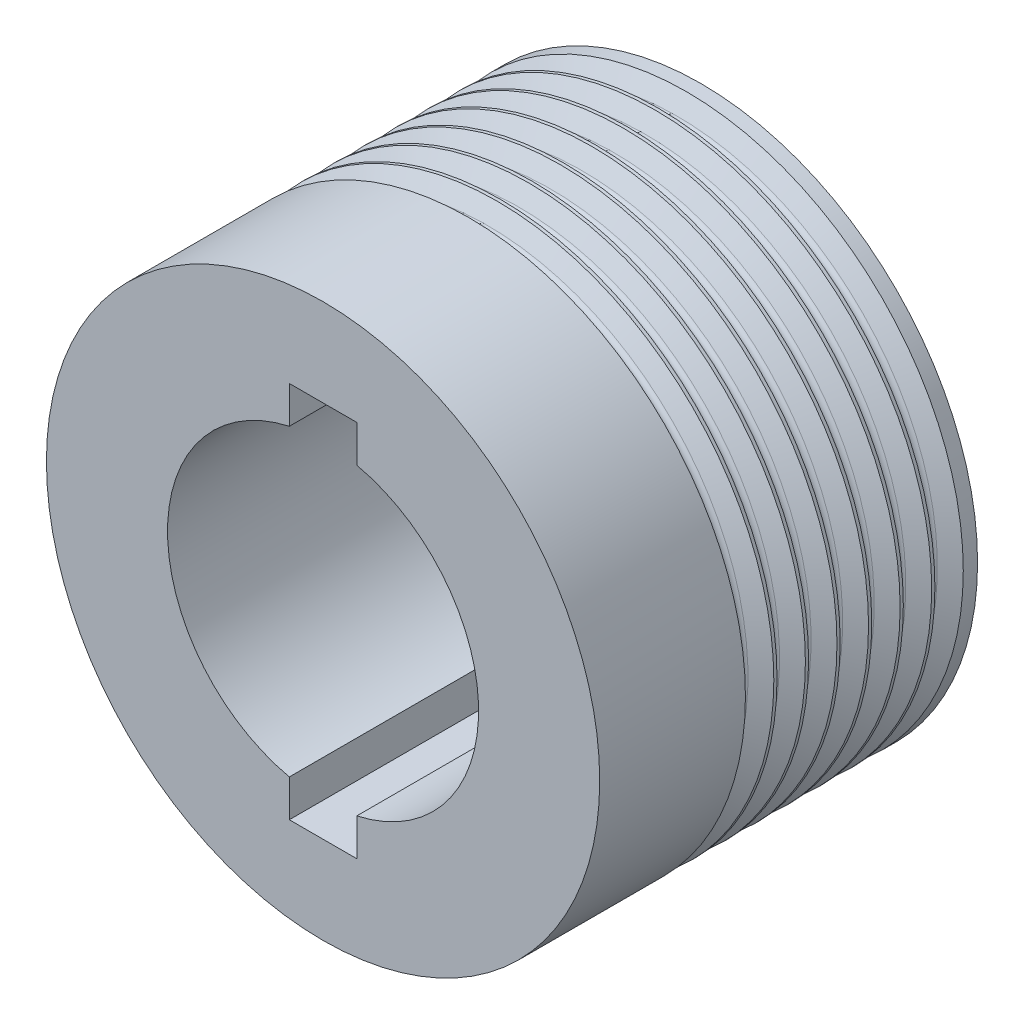
from build123d import *

# Parameters (mm, degrees)
SKETCH_1_R          = 20.5
SKETCH_1_R_2        = 11.525
EXTRUDE_1_DEPTH     = 28
SKETCH_3_W          = 5
SKETCH_3_H          = 28
CUT_EXTRUDE_1_DEPTH = 29


with BuildPart() as part:
    # 草图1 → 凸台-拉伸1 (new body)
    with BuildSketch(Plane.XY):
        Circle(SKETCH_1_R)
        Circle(SKETCH_1_R_2, mode=Mode.SUBTRACT)
    extrude(amount=EXTRUDE_1_DEPTH)

    # 草图2 → 切除-旋转1 (revolve, cut)
    with BuildSketch(Plane(origin=(0, 0, 0), x_dir=(0, 0, -1), z_dir=(1, 0, 0))):
        with BuildLine():
            Line((-3.22, 20.6), (-1, 20.6))
            Line((-1, 20.6), (-1.766239155, 19.29))
            ThreePointArc((-1.766239155, 19.29), (-2.111857315, 19.091955976), (-2.45713375, 19.290595176))
            Line((-2.45713375, 19.290595176), (-3.22, 20.6))
        make_face()
        with BuildLine():
            Line((-3.34, 20.6), (-4.106239155, 19.29))
            ThreePointArc((-4.106239155, 19.29), (-4.451857315, 19.091955976), (-4.79713375, 19.290595176))
            Line((-4.79713375, 19.290595176), (-5.56, 20.6))
            Line((-5.56, 20.6), (-3.34, 20.6))
        make_face()
        with BuildLine():
            Line((-5.68, 20.6), (-6.446239155, 19.29))
            ThreePointArc((-6.446239155, 19.29), (-6.791857315, 19.091955976), (-7.13713375, 19.290595176))
            Line((-7.13713375, 19.290595176), (-7.9, 20.6))
            Line((-7.9, 20.6), (-5.68, 20.6))
        make_face()
        with BuildLine():
            Line((-8.02, 20.6), (-8.786239155, 19.29))
            ThreePointArc((-8.786239155, 19.29), (-9.131857315, 19.091955976), (-9.47713375, 19.290595176))
            Line((-9.47713375, 19.290595176), (-10.24, 20.6))
            Line((-10.24, 20.6), (-8.02, 20.6))
        make_face()
        with BuildLine():
            Line((-10.36, 20.6), (-11.126239155, 19.29))
            ThreePointArc((-11.126239155, 19.29), (-11.471857315, 19.091955976), (-11.81713375, 19.290595176))
            Line((-11.81713375, 19.290595176), (-12.58, 20.6))
            Line((-12.58, 20.6), (-10.36, 20.6))
        make_face()
        with BuildLine():
            Line((-12.7, 20.6), (-13.466239155, 19.29))
            ThreePointArc((-13.466239155, 19.29), (-13.811857315, 19.091955976), (-14.15713375, 19.290595176))
            Line((-14.15713375, 19.290595176), (-14.92, 20.6))
            Line((-14.92, 20.6), (-12.7, 20.6))
        make_face()
        with BuildLine():
            Line((-15.04, 20.6), (-15.806239155, 19.29))
            ThreePointArc((-15.806239155, 19.29), (-16.151857315, 19.091955976), (-16.49713375, 19.290595176))
            Line((-16.49713375, 19.290595176), (-17.26, 20.6))
            Line((-17.26, 20.6), (-15.04, 20.6))
        make_face()
    revolve(axis=Axis((0, 0, 0), (0, 0, 1)), mode=Mode.SUBTRACT)

    # 草图3 → 切除-拉伸1 (cut, through all)
    with BuildSketch(Plane(origin=(0, 0, 0), x_dir=(-1, 0, 0), z_dir=(0, 0, -1))):
        Rectangle(SKETCH_3_W, SKETCH_3_H)
    extrude(amount=-CUT_EXTRUDE_1_DEPTH, mode=Mode.SUBTRACT)


solid = part.part
